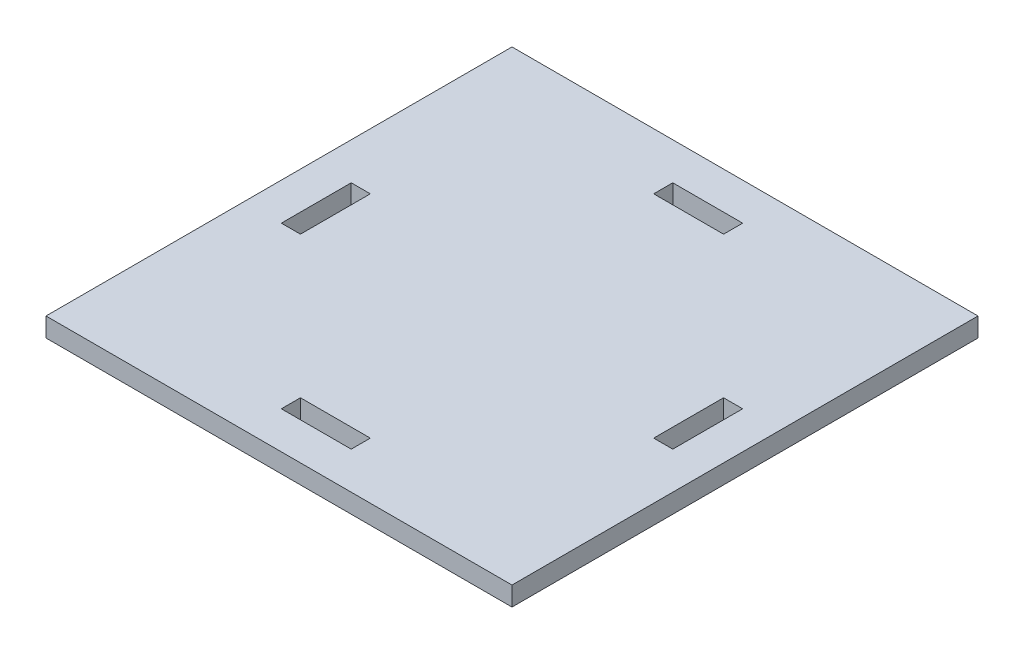
from build123d import *

# Parameters (mm, degrees)
SKETCH1_W           = 100
SKETCH1_H           = 100
SKETCH1_W_2         = 15
SKETCH1_H_2         = 4.1
SKETCH1_W_3         = 4.1
SKETCH1_H_3         = 15
BOSS_EXTRUDE1_DEPTH = 4.1


with BuildPart() as part:
    # Sketch1 → Boss-Extrude1 (new body)
    with BuildSketch(Plane(origin=(0, 0, 0), x_dir=(1, 0, 0), z_dir=(0, 1, 0))):
        with Locations((50, 50)):
            Rectangle(SKETCH1_W, SKETCH1_H)
        with Locations((50, 10.05)):
            Rectangle(SKETCH1_W_2, SKETCH1_H_2, mode=Mode.SUBTRACT)
        with Locations((50, 89.95)):
            Rectangle(SKETCH1_W_2, SKETCH1_H_2, mode=Mode.SUBTRACT)
        with Locations((10.05, 50)):
            Rectangle(SKETCH1_W_3, SKETCH1_H_3, mode=Mode.SUBTRACT)
        with Locations((89.95, 50)):
            Rectangle(SKETCH1_W_3, SKETCH1_H_3, mode=Mode.SUBTRACT)
    extrude(amount=BOSS_EXTRUDE1_DEPTH)


solid = part.part
